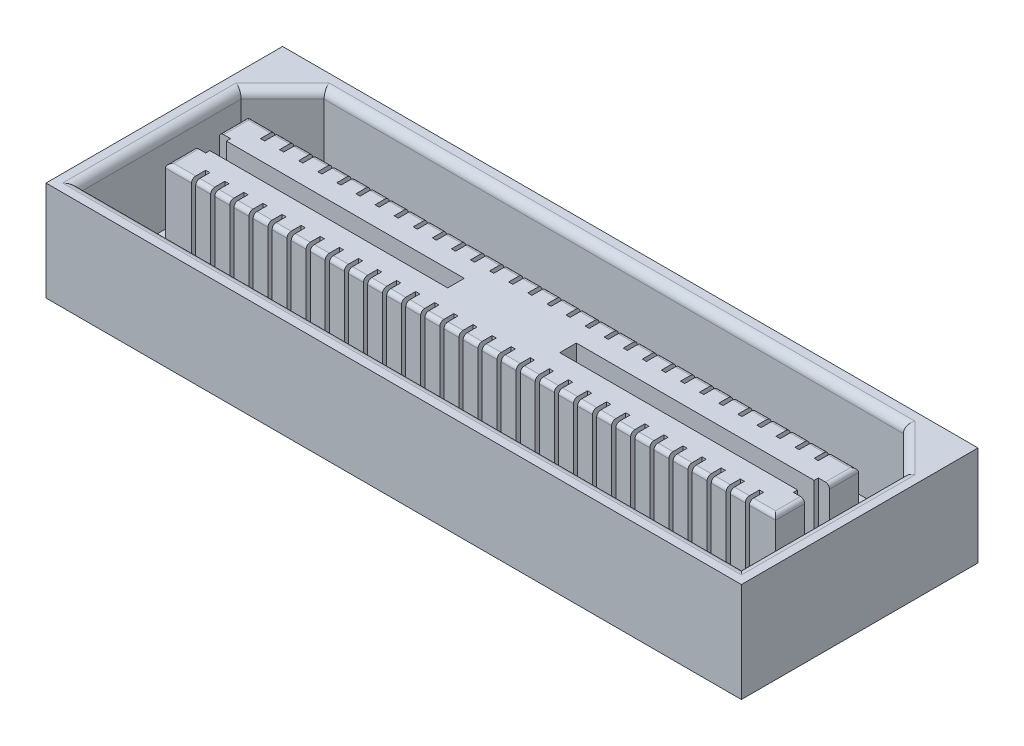
from build123d import *

# Parameters (mm, degrees)
SKETCH1_W           = 21.27758
SKETCH1_H           = 7.239
BOSS_EXTRUDE1_DEPTH = 3.048
CUT_EXTRUDE1_DEPTH  = 2.54
FILLET1_R           = 0.127
FILLET2_R           = 0.254
SKETCH3_W           = 0.127
SKETCH3_H           = 0.6096
CUT_EXTRUDE2_DEPTH  = 3.048


with BuildPart() as part:
    # Sketch1 → Boss-Extrude1 (new body)
    with BuildSketch(Plane(origin=(0, 0, 0), x_dir=(1, 0, 0), z_dir=(0, 1, 0))):
        with Locations((10.63879, 3.6195)):
            Rectangle(SKETCH1_W, SKETCH1_H)
    extrude(amount=BOSS_EXTRUDE1_DEPTH)

    # Sketch2 → Cut-Extrude1 (cut)
    with BuildSketch(Plane(origin=(0, 3.048, 0), x_dir=(1, 0, 0), z_dir=(0, 1, 0))):
        Polygon((0.508, 5.461), (1.778, 6.731), (19.49958, 6.731), (20.76958, 5.461), (20.76958, 0.508), (0.508, 0.508), align=None)
        Polygon((1.64719, 3.8735), (8.92429, 3.8735), (8.92429, 3.3655), (1.64719, 3.3655), (1.64719, 3.2385), (1.30429, 3.2385), (1.30429, 2.3495), (19.97329, 2.3495), (19.97329, 3.2385), (19.63039, 3.2385), (19.63039, 3.3655), (12.35329, 3.3655), (12.35329, 3.8735), (19.63039, 3.8735), (19.63039, 4.0005), (19.97329, 4.0005), (19.97329, 4.8895), (1.30429, 4.8895), (1.30429, 4.0005), (1.64719, 4.0005), align=None, mode=Mode.SUBTRACT)
    extrude(amount=-CUT_EXTRUDE1_DEPTH, mode=Mode.SUBTRACT)

    # Fillet1
    fillet1_edges = [part.edges().sort_by_distance(p)[0] for p in [
        (1.30429, 3.048, -4.445),
        (10.63879, 3.048, -4.8895),
        (19.97329, 3.048, -4.445),
        (19.97329, 3.048, -2.794),
        (10.63879, 3.048, -2.3495),
        (1.30429, 3.048, -2.794),
    ]]
    fillet(fillet1_edges, radius=FILLET1_R)

    # Fillet2
    fillet2_edges = [part.edges().sort_by_distance(p)[0] for p in [
        (20.76958, 3.048, -2.9845),
        (20.13458, 3.048, -6.096),
        (10.63879, 3.048, -6.731),
        (1.143, 3.048, -6.096),
        (0.508, 3.048, -2.9845),
        (10.63879, 3.048, -0.508),
    ]]
    fillet(fillet2_edges, radius=FILLET2_R)

    # Sketch3 → Cut-Extrude2 (cut)
    with BuildSketch(Plane(origin=(0, 3.048, 0), x_dir=(1, 0, 0), z_dir=(0, 1, 0))):
        with Locations((2.75209, 2.4765)):
            Rectangle(SKETCH3_W, SKETCH3_H)
        with Locations((2.16789, 2.4765)):
            Rectangle(SKETCH3_W, SKETCH3_H)
        with Locations((3.33629, 2.4765)):
            Rectangle(SKETCH3_W, SKETCH3_H)
        with Locations((3.92049, 2.4765)):
            Rectangle(SKETCH3_W, SKETCH3_H)
        with Locations((4.50469, 2.4765)):
            Rectangle(SKETCH3_W, SKETCH3_H)
        with Locations((5.08889, 2.4765)):
            Rectangle(SKETCH3_W, SKETCH3_H)
        with Locations((5.67309, 2.4765)):
            Rectangle(SKETCH3_W, SKETCH3_H)
        with Locations((6.25729, 2.4765)):
            Rectangle(SKETCH3_W, SKETCH3_H)
        with Locations((6.84149, 2.4765)):
            Rectangle(SKETCH3_W, SKETCH3_H)
        with Locations((7.42569, 2.4765)):
            Rectangle(SKETCH3_W, SKETCH3_H)
        with Locations((8.00989, 2.4765)):
            Rectangle(SKETCH3_W, SKETCH3_H)
        with Locations((8.59409, 2.4765)):
            Rectangle(SKETCH3_W, SKETCH3_H)
        with Locations((9.17829, 2.4765)):
            Rectangle(SKETCH3_W, SKETCH3_H)
        with Locations((9.76249, 2.4765)):
            Rectangle(SKETCH3_W, SKETCH3_H)
        with Locations((10.34669, 2.4765)):
            Rectangle(SKETCH3_W, SKETCH3_H)
        with Locations((10.93089, 2.4765)):
            Rectangle(SKETCH3_W, SKETCH3_H)
        with Locations((11.51509, 2.4765)):
            Rectangle(SKETCH3_W, SKETCH3_H)
        with Locations((12.09929, 2.4765)):
            Rectangle(SKETCH3_W, SKETCH3_H)
        with Locations((12.68349, 2.4765)):
            Rectangle(SKETCH3_W, SKETCH3_H)
        with Locations((13.26769, 2.4765)):
            Rectangle(SKETCH3_W, SKETCH3_H)
        with Locations((13.85189, 2.4765)):
            Rectangle(SKETCH3_W, SKETCH3_H)
        with Locations((14.43609, 2.4765)):
            Rectangle(SKETCH3_W, SKETCH3_H)
        with Locations((15.02029, 2.4765)):
            Rectangle(SKETCH3_W, SKETCH3_H)
        with Locations((15.60449, 2.4765)):
            Rectangle(SKETCH3_W, SKETCH3_H)
        with Locations((16.18869, 2.4765)):
            Rectangle(SKETCH3_W, SKETCH3_H)
        with Locations((16.77289, 2.4765)):
            Rectangle(SKETCH3_W, SKETCH3_H)
        with Locations((17.35709, 2.4765)):
            Rectangle(SKETCH3_W, SKETCH3_H)
        with Locations((17.94129, 2.4765)):
            Rectangle(SKETCH3_W, SKETCH3_H)
        with Locations((18.52549, 2.4765)):
            Rectangle(SKETCH3_W, SKETCH3_H)
        with Locations((19.10969, 2.4765)):
            Rectangle(SKETCH3_W, SKETCH3_H)
        with Locations((19.10969, 4.7625)):
            Rectangle(SKETCH3_W, SKETCH3_H)
        with Locations((18.52549, 4.7625)):
            Rectangle(SKETCH3_W, SKETCH3_H)
        with Locations((17.94129, 4.7625)):
            Rectangle(SKETCH3_W, SKETCH3_H)
        with Locations((17.35709, 4.7625)):
            Rectangle(SKETCH3_W, SKETCH3_H)
        with Locations((16.77289, 4.7625)):
            Rectangle(SKETCH3_W, SKETCH3_H)
        with Locations((16.18869, 4.7625)):
            Rectangle(SKETCH3_W, SKETCH3_H)
        with Locations((15.60449, 4.7625)):
            Rectangle(SKETCH3_W, SKETCH3_H)
        with Locations((15.02029, 4.7625)):
            Rectangle(SKETCH3_W, SKETCH3_H)
        with Locations((14.43609, 4.7625)):
            Rectangle(SKETCH3_W, SKETCH3_H)
        with Locations((13.85189, 4.7625)):
            Rectangle(SKETCH3_W, SKETCH3_H)
        with Locations((13.26769, 4.7625)):
            Rectangle(SKETCH3_W, SKETCH3_H)
        with Locations((12.68349, 4.7625)):
            Rectangle(SKETCH3_W, SKETCH3_H)
        with Locations((12.09929, 4.7625)):
            Rectangle(SKETCH3_W, SKETCH3_H)
        with Locations((11.51509, 4.7625)):
            Rectangle(SKETCH3_W, SKETCH3_H)
        with Locations((10.93089, 4.7625)):
            Rectangle(SKETCH3_W, SKETCH3_H)
        with Locations((10.34669, 4.7625)):
            Rectangle(SKETCH3_W, SKETCH3_H)
        with Locations((9.76249, 4.7625)):
            Rectangle(SKETCH3_W, SKETCH3_H)
        with Locations((9.17829, 4.7625)):
            Rectangle(SKETCH3_W, SKETCH3_H)
        with Locations((8.59409, 4.7625)):
            Rectangle(SKETCH3_W, SKETCH3_H)
        with Locations((8.00989, 4.7625)):
            Rectangle(SKETCH3_W, SKETCH3_H)
        with Locations((7.42569, 4.7625)):
            Rectangle(SKETCH3_W, SKETCH3_H)
        with Locations((6.84149, 4.7625)):
            Rectangle(SKETCH3_W, SKETCH3_H)
        with Locations((6.25729, 4.7625)):
            Rectangle(SKETCH3_W, SKETCH3_H)
        with Locations((5.67309, 4.7625)):
            Rectangle(SKETCH3_W, SKETCH3_H)
        with Locations((5.08889, 4.7625)):
            Rectangle(SKETCH3_W, SKETCH3_H)
        with Locations((4.50469, 4.7625)):
            Rectangle(SKETCH3_W, SKETCH3_H)
        with Locations((3.92049, 4.7625)):
            Rectangle(SKETCH3_W, SKETCH3_H)
        with Locations((3.33629, 4.7625)):
            Rectangle(SKETCH3_W, SKETCH3_H)
        with Locations((2.75209, 4.7625)):
            Rectangle(SKETCH3_W, SKETCH3_H)
        with Locations((2.16789, 4.7625)):
            Rectangle(SKETCH3_W, SKETCH3_H)
    extrude(amount=-CUT_EXTRUDE2_DEPTH, mode=Mode.SUBTRACT)


solid = part.part
